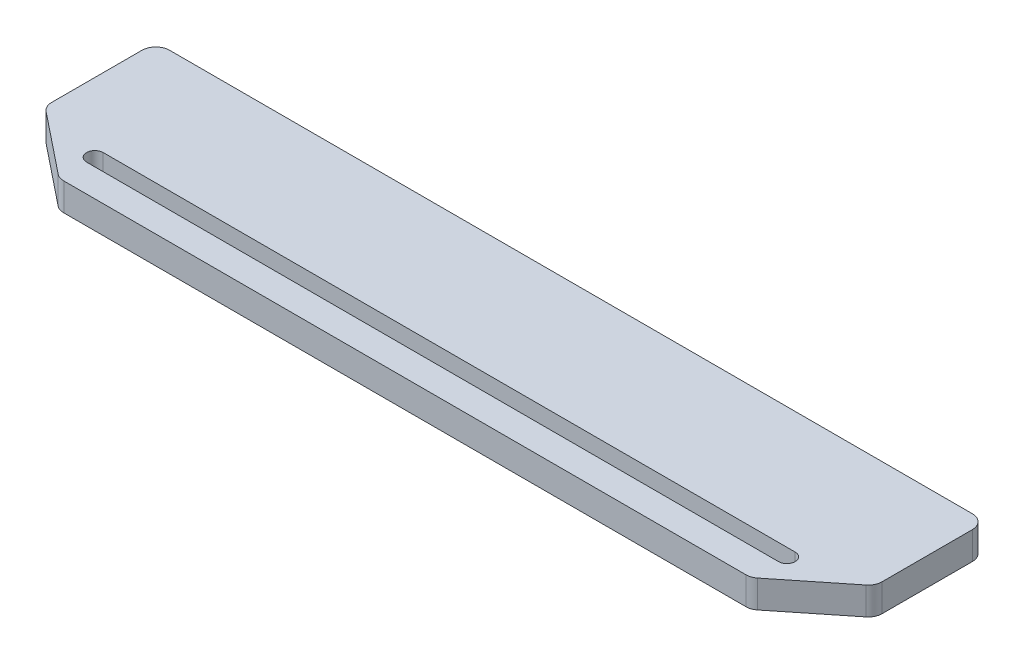
from build123d import *

# Parameters (mm, degrees)
BOSS_EXTRUDE1_DEPTH     = 10
CUT_EXTRUDE4_DEPTH      = 11
CUT_EXTRUDE4_DEPTH_BACK = 1


with BuildPart() as part:
    # Sketch1 → Boss-Extrude1 (new body)
    with BuildSketch(Plane(origin=(0, 0, 0), x_dir=(1, 0, 0), z_dir=(0, 1, 0))):
        with BuildLine():
            Line((0, -5), (0, -37.596875763))
            ThreePointArc((0, -37.596875763), (0.493483818, -39.762819415), (1.876524762, -41.50121981))
            Line((1.876524762, -41.50121981), (23.630430059, -58.904344047))
            ThreePointArc((23.630430059, -58.904344047), (25.09887059, -59.718141596), (26.753905297, -60))
            Line((26.753905297, -60), (273.246094703, -60))
            ThreePointArc((273.246094703, -60), (274.90112941, -59.718141596), (276.369569941, -58.904344047))
            Line((276.369569941, -58.904344047), (298.123475238, -41.50121981))
            ThreePointArc((298.123475238, -41.50121981), (299.506516182, -39.762819415), (300, -37.596875763))
            Line((300, -37.596875763), (300, -5))
            ThreePointArc((300, -5), (298.535533906, -1.464466094), (295, 0))
            Line((295, 0), (5, 0))
            ThreePointArc((5, 0), (1.464466094, -1.464466094), (0, -5))
        make_face()
    extrude(amount=BOSS_EXTRUDE1_DEPTH)

    # Sketch2 → Cut-Extrude4 (cut, two sides)
    with BuildSketch(Plane(origin=(0, 0, 0), x_dir=(1, 0, 0), z_dir=(0, 1, 0))) as cut_extrude4_sk:
        with BuildLine():
            Line((25, -44), (275, -44))
            ThreePointArc((275, -44), (278, -47), (275, -50))
            Line((275, -50), (25, -50))
            ThreePointArc((25, -50), (22, -47), (25, -44))
        make_face()
    extrude(amount=CUT_EXTRUDE4_DEPTH, mode=Mode.SUBTRACT)
    extrude(cut_extrude4_sk.sketch, amount=-CUT_EXTRUDE4_DEPTH_BACK, mode=Mode.SUBTRACT)


solid = part.part
